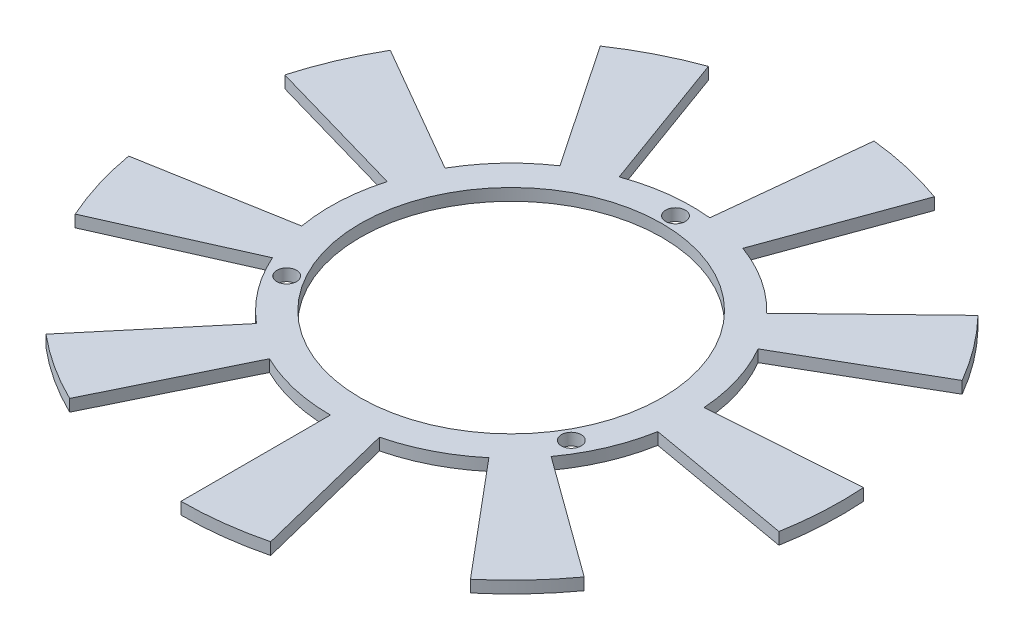
from build123d import *

# Parameters (mm, degrees)
SKETCH1_R           = 30.25
SKETCH1_R_2         = 25.25
EXTRUDE_THIN1_DEPTH = 2
SKETCH2_R           = 1.65
CUT_EXTRUDE3_DEPTH  = 10
BOSS_EXTRUDE1_DEPTH = 2


with BuildPart() as part:
    # Sketch1 → Extrude-Thin1 (new body)
    with BuildSketch(Plane(origin=(0, 0, 0), x_dir=(1, 0, 0), z_dir=(0, 1, 0))):
        Circle(SKETCH1_R)
        Circle(SKETCH1_R_2, mode=Mode.SUBTRACT)
    extrude(amount=-EXTRUDE_THIN1_DEPTH)

    # Sketch2 → Cut-Extrude3 (cut)
    with BuildSketch(Plane(origin=(0, 0, 0), x_dir=(1, 0, 0), z_dir=(0, 1, 0))):
        with Locations((0, 27.5)):
            Circle(SKETCH2_R)
        with Locations((23.815698604, -13.75)):
            Circle(SKETCH2_R)
        with Locations((-23.815698604, -13.75)):
            Circle(SKETCH2_R)
    extrude(amount=-CUT_EXTRUDE3_DEPTH, mode=Mode.SUBTRACT)

    # Sketch5 → Boss-Extrude1 (add)
    with BuildSketch(Plane.XZ.offset(2)):
        with BuildLine():
            Line((0, 55.25), (0, 30.25))
            ThreePointArc((0, 30.25), (3.686547638, 30.024521087), (7.318137342, 29.35144572))
            Line((7.318137342, 29.35144572), (13.366184732, 53.608838877))
            ThreePointArc((13.366184732, 53.608838877), (6.733281223, 54.838174878), (0, 55.25))
        make_face()
        with BuildLine():
            Line((35.514015435, 42.323955482), (19.444325193, 23.172844404))
            ThreePointArc((19.444325193, 23.172844404), (22.123449474, 20.630450392), (24.47276408, 17.780503882))
            Line((24.47276408, 17.780503882), (44.698188939, 32.475135189))
            ThreePointArc((44.698188939, 32.475135189), (40.407292014, 37.680409393), (35.514015435, 42.323955482))
        make_face()
        with BuildLine():
            Line((54.410628354, 9.594061816), (29.790434529, 5.252857374))
            ThreePointArc((29.790434529, 5.252857374), (30.208543426, 1.583162676), (30.17631252, -2.110133331))
            Line((30.17631252, -2.110133331), (55.115413777, -3.854045174))
            ThreePointArc((55.115413777, -3.854045174), (55.174281795, 2.891561582), (54.410628354, 9.594061816))
        make_face()
        with BuildLine():
            Line((47.847903559, -27.625), (26.197268464, -15.125))
            ThreePointArc((26.197268464, -15.125), (24.158724179, -18.20490445), (21.76002896, -21.013415706))
            Line((21.76002896, -21.013415706), (39.743523969, -38.379874968))
            ThreePointArc((39.743523969, -38.379874968), (44.12461193, -33.250280029), (47.847903559, -27.625))
        make_face()
        with BuildLine():
            Line((18.896612919, -51.918017298), (10.346109336, -28.425701779))
            ThreePointArc((10.346109336, -28.425701779), (6.804769394, -29.47469446), (3.161986014, -30.084287335))
            Line((3.161986014, -30.084287335), (5.775197596, -54.947334719))
            ThreePointArc((5.775197596, -54.947334719), (12.428545752, -53.833946079), (18.896612919, -51.918017298))
        make_face()
        with BuildLine():
            Line((-18.896612919, -51.918017298), (-10.346109336, -28.425701779))
            ThreePointArc((-10.346109336, -28.425701779), (-13.733212617, -26.952947357), (-16.91558533, -25.07838657))
            Line((-16.91558533, -25.07838657), (-30.895407917, -45.804325884))
            ThreePointArc((-30.895407917, -45.804325884), (-25.082975111, -49.228110461), (-18.896612919, -51.918017298))
        make_face()
        with BuildLine():
            Line((-47.847903559, -27.625), (-26.197268464, -15.125))
            ThreePointArc((-26.197268464, -15.125), (-27.845271817, -11.819616637), (-29.078166302, -8.338030013))
            Line((-29.078166302, -8.338030013), (-53.109708701, -15.228963909))
            ThreePointArc((-53.109708701, -15.228963909), (-50.857893153, -21.587894849), (-47.847903559, -27.625))
        make_face()
        with BuildLine():
            Line((-54.410628354, 9.594061816), (-29.790434529, 5.252857374))
            ThreePointArc((-29.790434529, 5.252857374), (-28.928218868, 8.844244068), (-27.634750094, 12.303783453))
            Line((-27.634750094, 12.303783453), (-50.473386535, 22.47219953))
            ThreePointArc((-50.473386535, 22.47219953), (-52.835837767, 16.153536686), (-54.410628354, 9.594061816))
        make_face()
        with BuildLine():
            Line((-35.514015435, 42.323955482), (-19.444325193, 23.172844404))
            ThreePointArc((-19.444325193, 23.172844404), (-16.475330809, 25.36978468), (-13.26072719, 27.188519901))
            Line((-13.26072719, 27.188519901), (-24.22000586, 49.658371058))
            ThreePointArc((-24.22000586, 49.658371058), (-30.091306685, 46.336548879), (-35.514015435, 42.323955482))
        make_face()
    extrude(amount=-BOSS_EXTRUDE1_DEPTH)


solid = part.part
